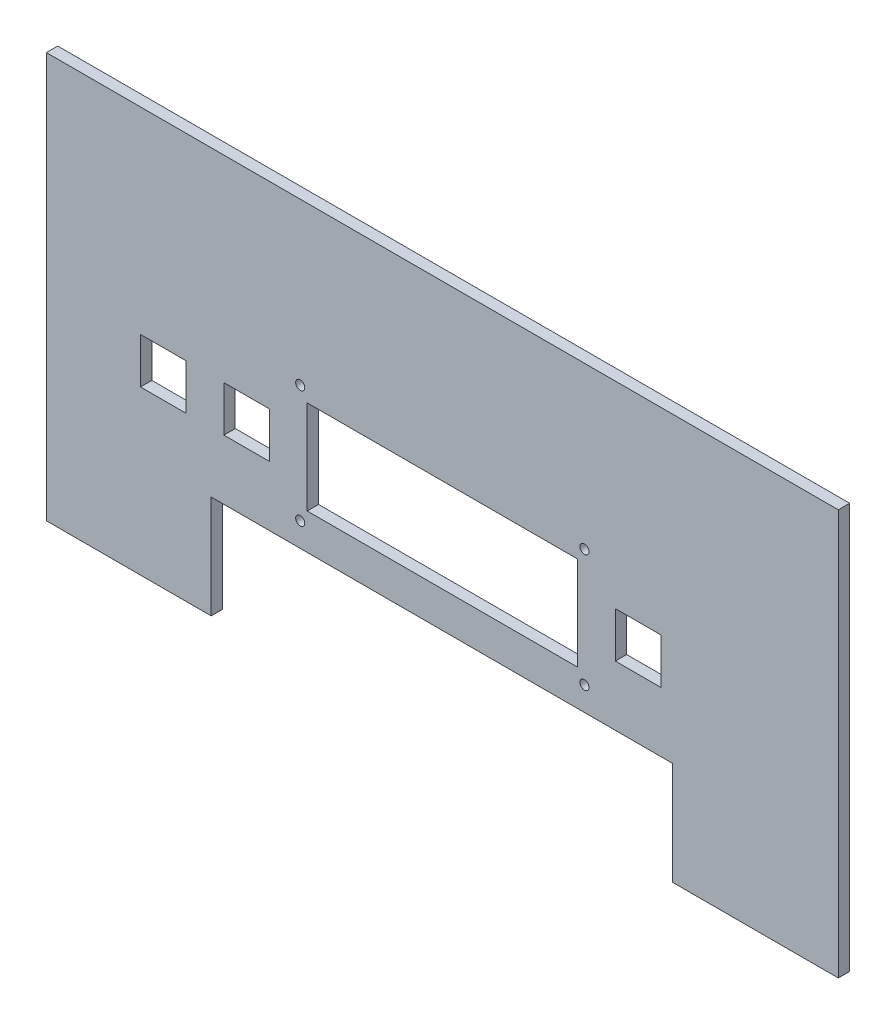
from build123d import *

# Parameters (mm, degrees)
SKETCH1_W           = 209
SKETCH1_H           = 107
SKETCH1_R           = 1.2
SKETCH1_W_2         = 71.3
SKETCH1_H_2         = 24.7
BOSS_EXTRUDE1_DEPTH = 3
SKETCH3_W           = 121.70473961
SKETCH3_H           = 27.18
CUT_EXTRUDE1_DEPTH  = 4
SKETCH4_W           = 12
SKETCH4_H           = 12
CUT_EXTRUDE2_DEPTH  = 4


with BuildPart() as part:
    # Sketch1 → Boss-Extrude1 (new body)
    with BuildSketch(Plane.XY):
        Rectangle(SKETCH1_W, SKETCH1_H)
        with Locations((-37.5, 11)):
            Circle(SKETCH1_R, mode=Mode.SUBTRACT)
        with Locations((37.5, 11)):
            Circle(SKETCH1_R, mode=Mode.SUBTRACT)
        with Locations((37.5, -20)):
            Circle(SKETCH1_R, mode=Mode.SUBTRACT)
        with Locations((-37.5, -20)):
            Circle(SKETCH1_R, mode=Mode.SUBTRACT)
        with Locations((0, -4.5)):
            Rectangle(SKETCH1_W_2, SKETCH1_H_2, mode=Mode.SUBTRACT)
    extrude(amount=BOSS_EXTRUDE1_DEPTH)

    # Sketch3 → Cut-Extrude1 (cut, through all)
    with BuildSketch(Plane.XY.offset(3)):
        with Locations((-0.147630195, -39.91)):
            Rectangle(SKETCH3_W, SKETCH3_H)
    extrude(amount=-CUT_EXTRUDE1_DEPTH, mode=Mode.SUBTRACT)

    # Sketch4 → Cut-Extrude2 (cut, through all)
    with BuildSketch(Plane.XY.offset(3)):
        with Locations((-51.65, -4.5)):
            Rectangle(SKETCH4_W, SKETCH4_H)
        with Locations((-73.65, -4.5)):
            Rectangle(SKETCH4_W, SKETCH4_H)
        with Locations((51.65, -4.5)):
            Rectangle(SKETCH4_W, SKETCH4_H)
    extrude(amount=-CUT_EXTRUDE2_DEPTH, mode=Mode.SUBTRACT)


solid = part.part
